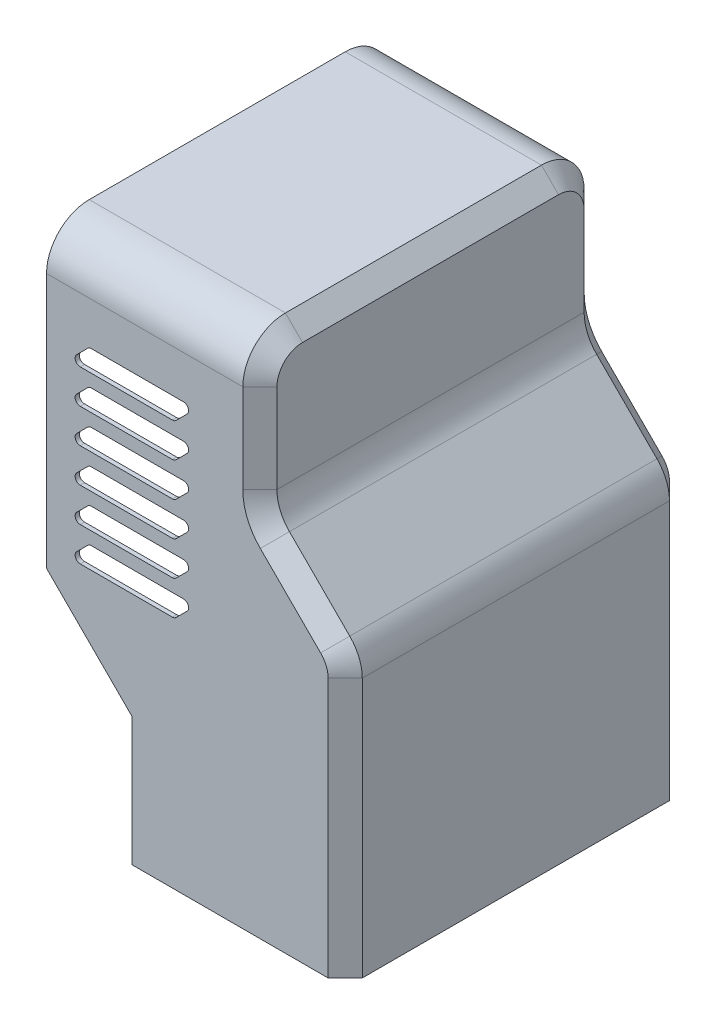
from build123d import *

# Parameters (mm, degrees)
BOSS_EXTRUDE1_DEPTH = 50.8
FILLET1_R           = 12.7
CHAMFER1_SIZE       = 5.08
SHELL1_T            = -1.27
CUT_EXTRUDE1_DEPTH  = 102.6


with BuildPart() as part:
    # Sketch1 → Boss-Extrude1 (new body, symmetric)
    with BuildSketch(Plane.XY):
        Polygon((0, 0), (63.5, 0), (63.5, 82.55), (38.1, 107.95), (38.1, 152.4), (-25.4, 152.4), (-25.4, 63.686926547), (0, 38.286926547), align=None)
    extrude(amount=BOSS_EXTRUDE1_DEPTH, both=True)

    # Fillet1
    fillet1_edges = [part.edges().sort_by_distance(p)[0] for p in [
        (38.1, 107.95, 0),
        (63.5, 82.55, 0),
        (6.35, 152.4, 50.8),
        (6.35, 152.4, -50.8),
    ]]
    fillet(fillet1_edges, radius=FILLET1_R)

    # Chamfer1
    chamfer1_edges = [part.edges().sort_by_distance(p)[0] for p in [
        (63.5, 38.644743879, -50.8),
        (63.5, 38.644743879, 50.8),
        (50.8, 95.25, -50.8),
        (50.8, 95.25, 50.8),
        (38.1, 126.455256121, -50.8),
        (62.533270063, 82.149567349, -50.8),
        (38.1, 126.455256121, 50.8),
        (62.533270063, 82.149567349, 50.8),
        (38.1, 152.4, 0),
        (38.1, 148.680256121, 47.080256121),
        (38.1, 148.680256121, -47.080256121),
        (39.066729937, 108.350432651, -50.8),
        (39.066729937, 108.350432651, 50.8),
    ]]
    chamfer(chamfer1_edges, length=CHAMFER1_SIZE)

    # Shell1
    shell1_openings = [part.faces().sort_by_distance(p)[0] for p in [
        (-12.7, 50.986926547, 0),
        (-25.4, 119.472394223, 0),
        (40.64, 0, 0),
        (0, 19.143463274, 0),
    ]]
    offset(amount=SHELL1_T, openings=shell1_openings, kind=Kind.INTERSECTION)

    # Sketch2 → Cut-Extrude1 (cut, through all)
    with BuildSketch(Plane.XY.offset(50.8)):
        with BuildLine():
            Line((-13.146369265, 126.553630735), (-16.448369265, 123.251630735))
            ThreePointArc((-16.448369265, 123.251630735), (-16.778730938, 121.590790449), (-15.370738531, 120.65))
            Line((-15.370738531, 120.65), (12.068738531, 120.65))
            ThreePointArc((12.068738531, 120.65), (12.651948082, 120.766007592), (13.146369265, 121.096369265))
            Line((13.146369265, 121.096369265), (16.448369265, 124.398369265))
            ThreePointArc((16.448369265, 124.398369265), (16.778730938, 126.059209551), (15.370738531, 127))
            Line((15.370738531, 127), (-12.068738531, 127))
            ThreePointArc((-12.068738531, 127), (-12.651948082, 126.883992408), (-13.146369265, 126.553630735))
        make_face()
        with BuildLine():
            Line((-13.146369265, 116.393630735), (-16.448369265, 113.091630735))
            ThreePointArc((-16.448369265, 113.091630735), (-16.778730938, 111.430790449), (-15.370738531, 110.49))
            Line((-15.370738531, 110.49), (12.068738531, 110.49))
            ThreePointArc((12.068738531, 110.49), (12.651948082, 110.606007592), (13.146369265, 110.936369265))
            Line((13.146369265, 110.936369265), (16.448369265, 114.238369265))
            ThreePointArc((16.448369265, 114.238369265), (16.778730938, 115.899209551), (15.370738531, 116.84))
            Line((15.370738531, 116.84), (-12.068738531, 116.84))
            ThreePointArc((-12.068738531, 116.84), (-12.651948082, 116.723992408), (-13.146369265, 116.393630735))
        make_face()
        with BuildLine():
            Line((-13.146369265, 106.233630735), (-16.448369265, 102.931630735))
            ThreePointArc((-16.448369265, 102.931630735), (-16.778730938, 101.270790449), (-15.370738531, 100.33))
            Line((-15.370738531, 100.33), (12.068738531, 100.33))
            ThreePointArc((12.068738531, 100.33), (12.651948082, 100.446007592), (13.146369265, 100.776369265))
            Line((13.146369265, 100.776369265), (16.448369265, 104.078369265))
            ThreePointArc((16.448369265, 104.078369265), (16.778730938, 105.739209551), (15.370738531, 106.68))
            Line((15.370738531, 106.68), (-12.068738531, 106.68))
            ThreePointArc((-12.068738531, 106.68), (-12.651948082, 106.563992408), (-13.146369265, 106.233630735))
        make_face()
        with BuildLine():
            Line((-13.146369265, 96.073630735), (-16.448369265, 92.771630735))
            ThreePointArc((-16.448369265, 92.771630735), (-16.778730938, 91.110790449), (-15.370738531, 90.17))
            Line((-15.370738531, 90.17), (12.068738531, 90.17))
            ThreePointArc((12.068738531, 90.17), (12.651948082, 90.286007592), (13.146369265, 90.616369265))
            Line((13.146369265, 90.616369265), (16.448369265, 93.918369265))
            ThreePointArc((16.448369265, 93.918369265), (16.778730938, 95.579209551), (15.370738531, 96.52))
            Line((15.370738531, 96.52), (-12.068738531, 96.52))
            ThreePointArc((-12.068738531, 96.52), (-12.651948082, 96.403992408), (-13.146369265, 96.073630735))
        make_face()
        with BuildLine():
            Line((-13.146369265, 85.913630735), (-16.448369265, 82.611630735))
            ThreePointArc((-16.448369265, 82.611630735), (-16.778730938, 80.950790449), (-15.370738531, 80.01))
            Line((-15.370738531, 80.01), (12.068738531, 80.01))
            ThreePointArc((12.068738531, 80.01), (12.651948082, 80.126007592), (13.146369265, 80.456369265))
            Line((13.146369265, 80.456369265), (16.448369265, 83.758369265))
            ThreePointArc((16.448369265, 83.758369265), (16.778730938, 85.419209551), (15.370738531, 86.36))
            Line((15.370738531, 86.36), (-12.068738531, 86.36))
            ThreePointArc((-12.068738531, 86.36), (-12.651948082, 86.243992408), (-13.146369265, 85.913630735))
        make_face()
        with BuildLine():
            Line((-13.146369265, 75.753630735), (-16.448369265, 72.451630735))
            ThreePointArc((-16.448369265, 72.451630735), (-16.778730938, 70.790790449), (-15.370738531, 69.85))
            Line((-15.370738531, 69.85), (12.068738531, 69.85))
            ThreePointArc((12.068738531, 69.85), (12.651948082, 69.966007592), (13.146369265, 70.296369265))
            Line((13.146369265, 70.296369265), (16.448369265, 73.598369265))
            ThreePointArc((16.448369265, 73.598369265), (16.778730938, 75.259209551), (15.370738531, 76.2))
            Line((15.370738531, 76.2), (-12.068738531, 76.2))
            ThreePointArc((-12.068738531, 76.2), (-12.651948082, 76.083992408), (-13.146369265, 75.753630735))
        make_face()
    extrude(amount=-CUT_EXTRUDE1_DEPTH, mode=Mode.SUBTRACT)


solid = part.part
